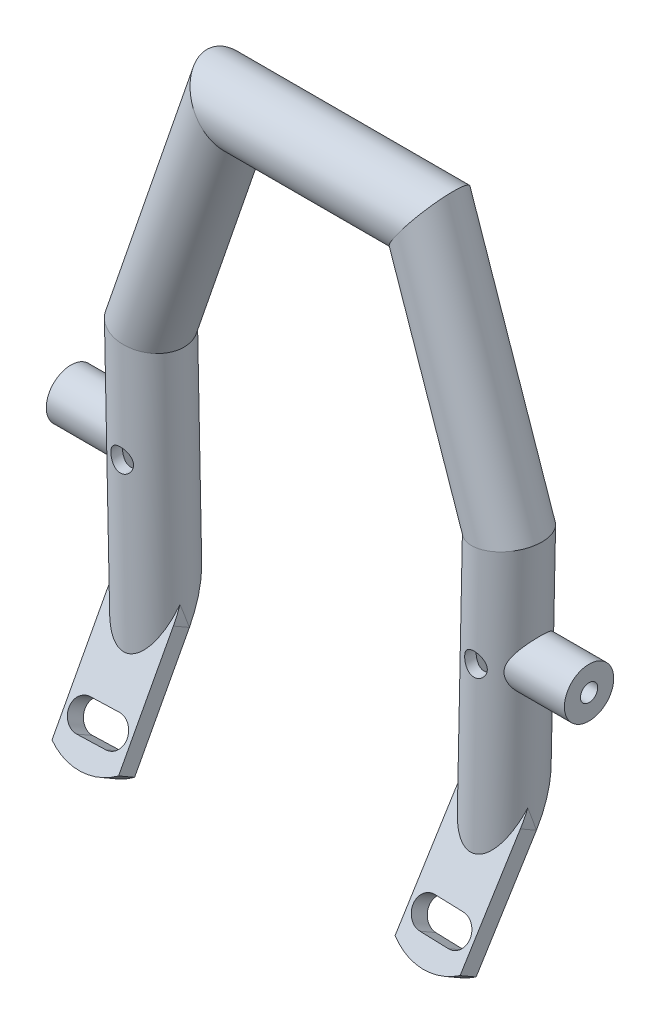
from build123d import *

# Parameters (mm, degrees)
ESQUISSE1_R                  = 8
ESQUISSE1_R_2                = 5.5
ENL_V_MAT_EXTRU_1_DEPTH      = 148.532891607
ENL_V_MAT_EXTRU_1_DEPTH_BACK = 148.532891607
EXTRUSION1_DEPTH             = 4.5
EXTRUSION2_REACH             = 182.37
EXTRUSION2_END_RADIUS        = 8
ESQUISSE6_R                  = 6
ESQUISSE6_R_2                = 2.1
ESQUISSE7_R                  = 2.75
ENL_V_MAT_EXTRU_2_DEPTH      = 153.903635959


with BuildPart() as part:
    # Balayage2: sweep along a path in Esquisse3
    with BuildLine(Plane.XY) as balayage2_path:
        Line((0, 122), (-18.5, 122))
        Line((-18.5, 122), (-35.5, 72.5))
        Line((-35.5, 72.5), (-34, 0))
    # Esquisse1 → Balayage2 (sweep)
    with BuildSketch(Plane(origin=(0, 0, 0), x_dir=(0, 0, -1), z_dir=(1, 0, 0))):
        with Locations((0, 130)):
            Circle(ESQUISSE1_R)
        with Locations((0, 130)):
            Circle(ESQUISSE1_R_2, mode=Mode.SUBTRACT)
    balayage2 = sweep(path=balayage2_path.line, transition=Transition.RIGHT)

    # Sym_trie1: Balayage2 across plane
    add(balayage2.mirror(Plane(origin=(0, 0, 0), x_dir=(0, 0, 1), z_dir=(1, 0, 0))))

    # Esquisse4 → Enl_v. mat.-Extru.1 (cut, two sides)
    with BuildSketch(Plane(origin=(0, 0, 0), x_dir=(0, 0, -1), z_dir=(1, 0, 0))) as enl_v_mat_extru_1_sk:
        Polygon((8, 27.712812921), (-8.191081955, -0.330963654), (8, -0.330963654), align=None)
    extrude(amount=ENL_V_MAT_EXTRU_1_DEPTH, mode=Mode.SUBTRACT)
    extrude(enl_v_mat_extru_1_sk.sketch, amount=-ENL_V_MAT_EXTRU_1_DEPTH_BACK, mode=Mode.SUBTRACT)

    # Esquisse5 → Extrusion1 (add)
    with BuildSketch(Plane(origin=(0, 0, 8), x_dir=(1, 0, 0), z_dir=(0, 0.49999999999999994, 0.8660254037844387))):
        with BuildLine():
            Line((50.286114316, 15.808931671), (49.617634889, -12.172209656))
            ThreePointArc((49.617634889, -12.172209656), (41.55994833, -14.4912998), (33.622198929, -11.790072997))
            Line((33.622198929, -11.790072997), (34.290678355, 16.191068329))
            add(Edge.make_bspline(
                [(50.286114316, 15.808931671), (50.668332755, 31.807790783), (42.670614775, 31.998859112), (34.672896795, 32.189927442), (34.290678355, 16.191068329)],
                knots=[4.71238898, 4.71238898, 4.71238898, 6.283185307, 6.283185307, 7.853981634, 7.853981634, 7.853981634], degree=2, weights=[1, 0.707106781, 1, 0.707106781, 1]))
        make_face()
        with BuildLine():
            Line((45.357494211, -2.07845785), (38.359490978, -1.911273062))
            ThreePointArc((38.359490978, -1.911273062), (34.776896967, -5.326682284), (38.19230619, -8.909276295))
            Line((38.19230619, -8.909276295), (45.190309423, -9.076461083))
            ThreePointArc((45.190309423, -9.076461083), (48.772903433, -5.661051861), (45.357494211, -2.07845785))
        make_face(mode=Mode.SUBTRACT)
        with BuildLine():
            Line((-34.290678355, 16.191068329), (-33.622198929, -11.790072997))
            ThreePointArc((-33.622198929, -11.790072997), (-41.55994833, -14.4912998), (-49.617634889, -12.172209656))
            Line((-49.617634889, -12.172209656), (-50.286114316, 15.808931671))
            add(Edge.make_bspline(
                [(-34.290678355, 16.191068329), (-34.672896795, 32.189927442), (-42.670614775, 31.998859112), (-50.668332755, 31.807790783), (-50.286114316, 15.808931671)],
                knots=[1.570796327, 1.570796327, 1.570796327, 3.141592654, 3.141592654, 4.71238898, 4.71238898, 4.71238898], degree=2, weights=[1, 0.707106781, 1, 0.707106781, 1]))
        make_face()
        with BuildLine():
            Line((-45.190309423, -9.076461083), (-38.19230619, -8.909276295))
            ThreePointArc((-38.19230619, -8.909276295), (-34.776896967, -5.326682284), (-38.359490978, -1.911273062))
            Line((-38.359490978, -1.911273062), (-45.357494211, -2.07845785))
            ThreePointArc((-45.357494211, -2.07845785), (-48.772903433, -5.661051861), (-45.190309423, -9.076461083))
        make_face(mode=Mode.SUBTRACT)
    extrude(amount=EXTRUSION1_DEPTH)

    # Extrusion2: up to this cylinder (the profile starts outside it)
    extrusion2_end = Plane(origin=(43.024056107, 49.413295391, 0), z_dir=(-0.020685228367733104, -0.9997860377737703, 0)) * Cylinder(EXTRUSION2_END_RADIUS, 381.74, mode=Mode.PRIVATE)
    # Esquisse6 → Extrusion2 (add, up to the surface)
    with BuildSketch(Plane(origin=(63, 0, 0), x_dir=(0, 0, -1), z_dir=(1, 0, 0)), mode=Mode.PRIVATE) as extrusion2_sk1:
        with Locations((0, 49)):
            Circle(ESQUISSE6_R)
        with Locations((0, 49)):
            Circle(ESQUISSE6_R_2, mode=Mode.SUBTRACT)
    extrusion2_tool1 = extrude(extrusion2_sk1.sketch, amount=-EXTRUSION2_REACH, mode=Mode.PRIVATE) - extrusion2_end
    extrusion2 = extrusion2_tool1.solids().sort_by_distance((63, 49, 5.830294))[0]
    add(extrusion2)

    # Sym_trie2: Extrusion2 across plane
    add(extrusion2.mirror(Plane(origin=(0, 0, 0), x_dir=(0, 0, 1), z_dir=(1, 0, 0))))

    # Esquisse7 → Enl_v. mat.-Extru.2 (cut, through all)
    with BuildSketch(Plane.XY):
        with Locations(Location((-43.015505168, 49, 0), (0, 0, 180))):
            Circle(ESQUISSE7_R)
        with Locations(Location((43.015505168, 49, 0), (0, 0, 180))):
            Circle(ESQUISSE7_R)
    extrude(amount=ENL_V_MAT_EXTRU_2_DEPTH, mode=Mode.SUBTRACT)


solid = part.part
